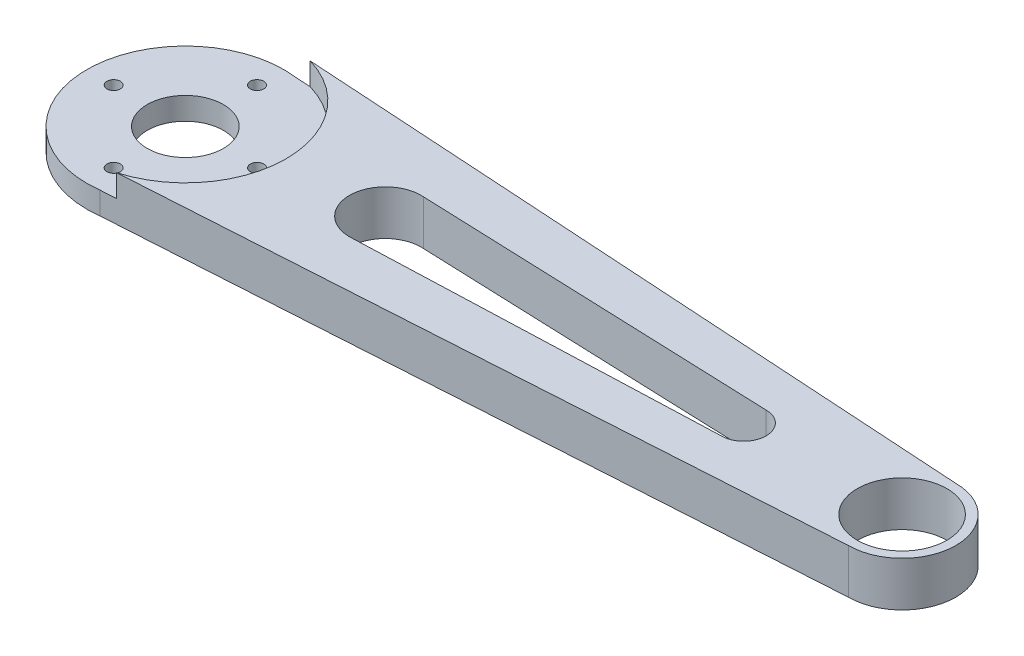
from build123d import *

# Parameters (mm, degrees)
SKETCH_1_R          = 11
EXTRUDE_1_DEPTH     = 5
SKETCH_1_R_2        = 6
EXTRUDE_1_2_DEPTH   = 5
EXTRUDE_3_DEPTH     = 5
SKETCH_4_R          = 11.25
CUT_EXTRUDE_1_DEPTH = 2.5
SKETCH_5_R          = 5
CUT_EXTRUDE_2_DEPTH = 6
SKETCH_6_R          = 4
SKETCH_6_R_2        = 2.5
CUT_EXTRUDE_3_DEPTH = 6
CUT_EXTRUDE_4_DEPTH = 6
SKETCH_8_R          = 0.747737987
SKETCH_8_R_2        = 0.75
CUT_EXTRUDE_5_DEPTH = 3.5
SKETCH_9_R          = 4.25
CUT_EXTRUDE_6_DEPTH = 3.5


with BuildPart() as part:
    # 草图1 → 凸台-拉伸1 (new body)
    with BuildSketch(Plane(origin=(0, 0, 0), x_dir=(1, 0, 0), z_dir=(0, 1, 0))):
        with Locations((-44.318784969, 0)):
            Circle(SKETCH_1_R)
    extrude(amount=EXTRUDE_1_DEPTH)



with BuildPart() as body_2:
    # 草图1 → Extrude 1 2 (new body)
    with BuildSketch(Plane(origin=(0, 0, 0), x_dir=(1, 0, 0), z_dir=(0, 1, 0))):
        with Locations((35.681215031, 0)):
            Circle(SKETCH_1_R_2)
    extrude(amount=EXTRUDE_1_2_DEPTH)


with BuildPart() as part_1:
    add(part.part)

    add(body_2.part)  # 凸台-拉伸3 merges body 2
    # 草图3 → 凸台-拉伸3 (add)
    with BuildSketch(Plane(origin=(0, 0, 0), x_dir=(1, 0, 0), z_dir=(0, 1, 0))):
        Polygon((-44.318784969, 11), (35.681215031, 6), (35.681215031, -6), (-44.318784969, -11), align=None)
    extrude(amount=EXTRUDE_3_DEPTH)

    # 草图4 → 切除-拉伸1 (cut)
    with BuildSketch(Plane(origin=(0, 5, 0), x_dir=(1, 0, 0), z_dir=(0, 1, 0))):
        with Locations((-44.318784969, 0)):
            Circle(SKETCH_4_R)
    extrude(amount=-CUT_EXTRUDE_1_DEPTH, mode=Mode.SUBTRACT)

    # 草图5 → 切除-拉伸2 (cut, through all)
    with BuildSketch(Plane(origin=(0, 5, 0), x_dir=(1, 0, 0), z_dir=(0, 1, 0))):
        with Locations((35.681215031, 0)):
            Circle(SKETCH_5_R)
    extrude(amount=-CUT_EXTRUDE_2_DEPTH, mode=Mode.SUBTRACT)

    # 草图6 → 切除-拉伸3 (cut, through all)
    with BuildSketch(Plane(origin=(0, 5, 0), x_dir=(1, 0, 0), z_dir=(0, 1, 0))):
        with Locations((-22, 0)):
            Circle(SKETCH_6_R)
        with Locations((18, 0)):
            Circle(SKETCH_6_R_2)
    extrude(amount=-CUT_EXTRUDE_3_DEPTH, mode=Mode.SUBTRACT)

    # 草图7 → 切除-拉伸4 (cut, through all)
    with BuildSketch(Plane(origin=(0, 5, 0), x_dir=(1, 0, 0), z_dir=(0, 1, 0))):
        Polygon((-22, 4), (18, 2.5), (18, -2.5), (-22, -4), align=None)
    extrude(amount=-CUT_EXTRUDE_4_DEPTH, mode=Mode.SUBTRACT)

    # 草图8 → 切除-拉伸5 (cut, through all)
    with BuildSketch(Plane(origin=(0, 2.5, 0), x_dir=(1, 0, 0), z_dir=(0, 1, 0))):
        with Locations((-52.318784969, 0)):
            Circle(SKETCH_8_R)
        with Locations((-36.318784969, 0)):
            Circle(SKETCH_8_R)
        with Locations((-44.318784969, 8)):
            Circle(SKETCH_8_R_2)
        with Locations((-44.318784969, -8)):
            Circle(SKETCH_8_R_2)
    extrude(amount=-CUT_EXTRUDE_5_DEPTH, mode=Mode.SUBTRACT)

    # 草图9 → 切除-拉伸6 (cut, through all)
    with BuildSketch(Plane(origin=(0, 2.5, 0), x_dir=(1, 0, 0), z_dir=(0, 1, 0))):
        with Locations((-44.318784969, 0)):
            Circle(SKETCH_9_R)
    extrude(amount=-CUT_EXTRUDE_6_DEPTH, mode=Mode.SUBTRACT)


solid = part_1.part
